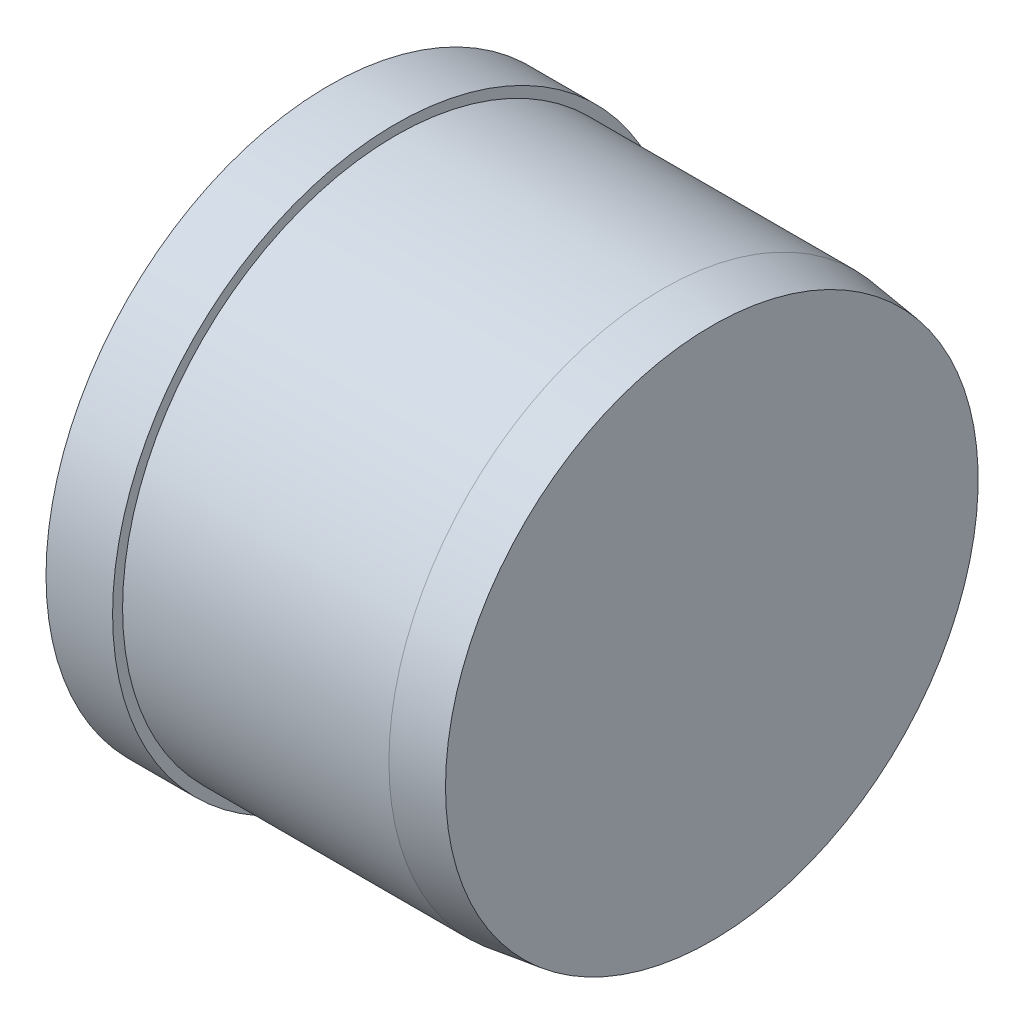
from build123d import *


with BuildPart() as part:
    # Sketch1 → Revolve1 (revolve)
    with BuildSketch(Plane.XY):
        Polygon((57.5, 0), (57.5, 40), (50, 41), (10, 41), (10, 42.5), (0, 42.5), (0, 0), align=None)
    revolve(axis=Axis((0, 0, 0), (1, 0, 0)))


solid = part.part
